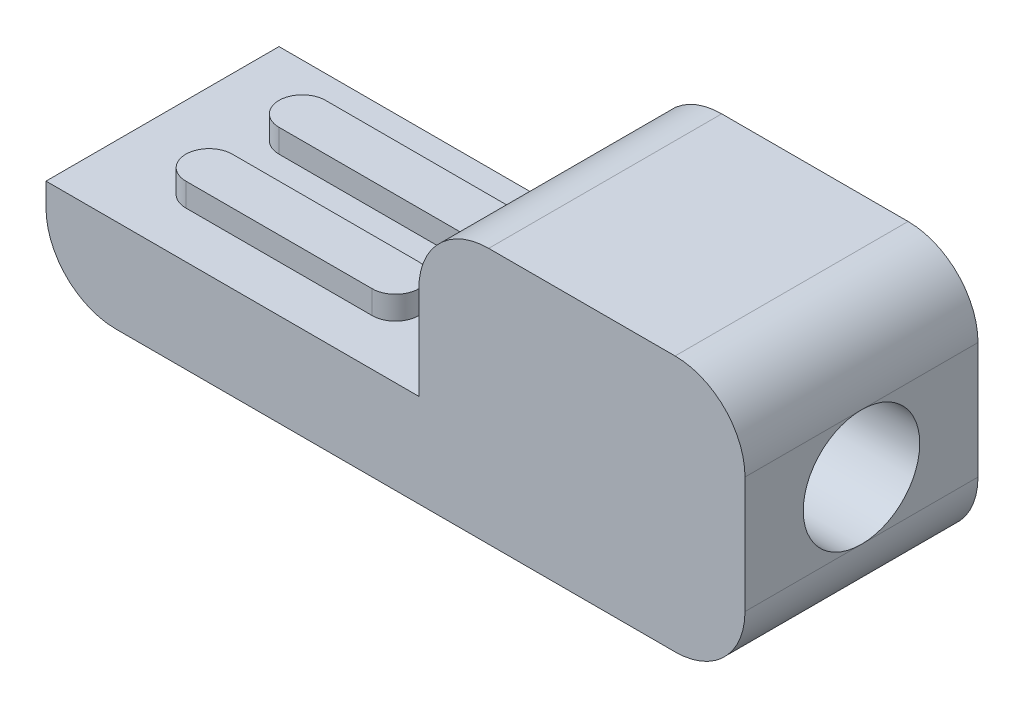
from build123d import *

# Parameters (mm, degrees)
EXTRUDE_1_DEPTH        = 2.5
FILLET_1_R             = 1.5
HOLE_WIZARD_M3_1_D     = 2.5
HOLE_WIZARD_M3_1_DEPTH = 5
HOLE_WIZARD_M3_1_TIP   = 0.751075774
EXTRUDE_2_DEPTH        = 0.5


with BuildPart() as part:
    # 스케치1 → 보스-돌출1 (new body, symmetric)
    with BuildSketch(Plane.XY):
        Polygon((0, 0), (-15, 0), (-15, 2), (-7, 2), (-7, 5.5), (0, 5.5), align=None)
    extrude(amount=EXTRUDE_1_DEPTH, both=True)

    # 필렛1
    fillet_1_edges = [part.edges().sort_by_distance(p)[0] for p in [
        (0, 0, 0),
        (-15, 0, 0),
        (-7, 5.5, 0),
        (0, 5.5, 0),
    ]]
    fillet(fillet_1_edges, radius=FILLET_1_R)

    # M3 나사 구멍1
    with Locations(Plane(origin=(0, 0, 0), x_dir=(0, 0, -1), z_dir=(1, 0, 0))):
        with Locations((0, 2.75)):
            Hole(HOLE_WIZARD_M3_1_D / 2, depth=HOLE_WIZARD_M3_1_DEPTH)
            with Locations((0, 0, -(HOLE_WIZARD_M3_1_DEPTH + HOLE_WIZARD_M3_1_TIP / 2))):  # 118° drill point
                Cone(0, HOLE_WIZARD_M3_1_D / 2, HOLE_WIZARD_M3_1_TIP, mode=Mode.SUBTRACT)

    # 스케치4 → 보스-돌출2 (add)
    with BuildSketch(Plane(origin=(0, 2, 0), x_dir=(1, 0, 0), z_dir=(0, 1, 0))):
        with BuildLine():
            Line((-13, 1.5), (-9, 1.5))
            ThreePointArc((-9, 1.5), (-8.5, 1), (-9, 0.5))
            Line((-9, 0.5), (-13, 0.5))
            ThreePointArc((-13, 0.5), (-13.5, 1), (-13, 1.5))
        make_face()
        with BuildLine():
            Line((-13, -1.5), (-9, -1.5))
            ThreePointArc((-9, -1.5), (-8.5, -1), (-9, -0.5))
            Line((-9, -0.5), (-13, -0.5))
            ThreePointArc((-13, -0.5), (-13.5, -1), (-13, -1.5))
        make_face()
    extrude(amount=EXTRUDE_2_DEPTH)


solid = part.part
